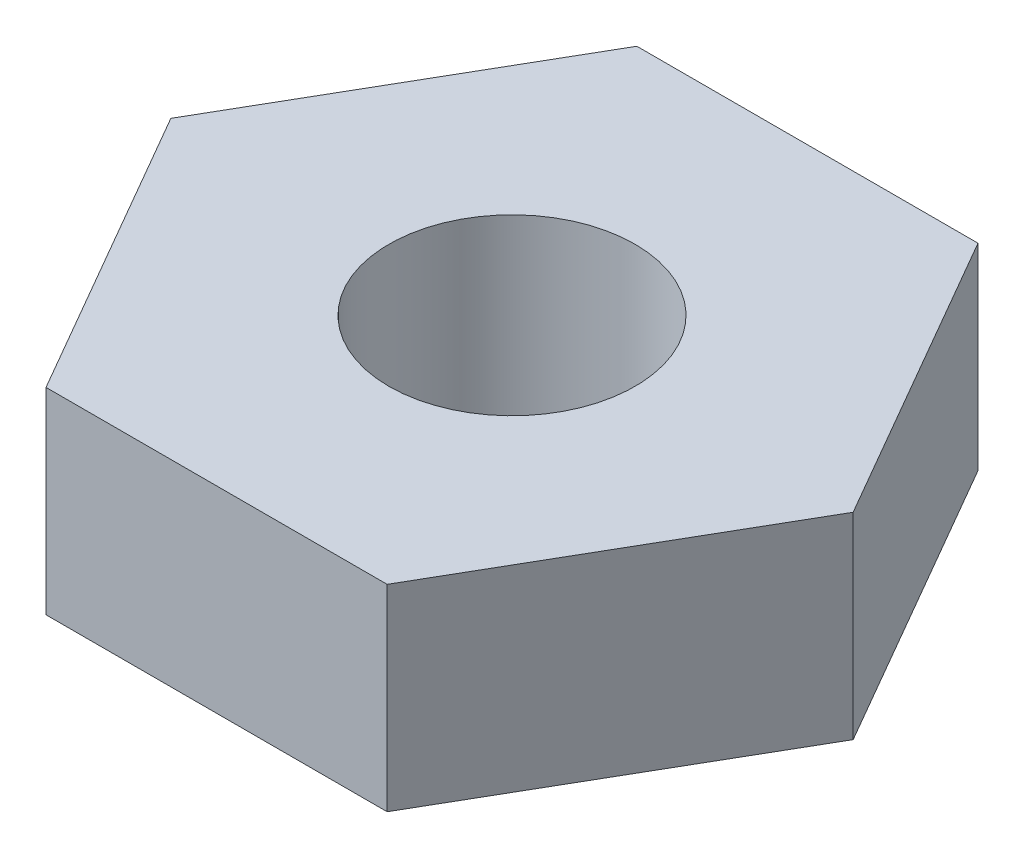
from build123d import *

# Parameters (mm, degrees)
SKETCH1_R      = 1
EXTRUDE1_DEPTH = 1.6


with BuildPart() as part:
    # Sketch1 → Extrude1 (new body)
    with BuildSketch(Plane(origin=(0, 0, 0), x_dir=(1, 0, 0), z_dir=(0, 1, 0))):
        Polygon((2.771281292, 0), (1.385640646, 2.4), (-1.385640646, 2.4), (-2.771281292, 0), (-1.385640646, -2.4), (1.385640646, -2.4), align=None)
        Circle(SKETCH1_R, mode=Mode.SUBTRACT)
    extrude(amount=EXTRUDE1_DEPTH)


solid = part.part
